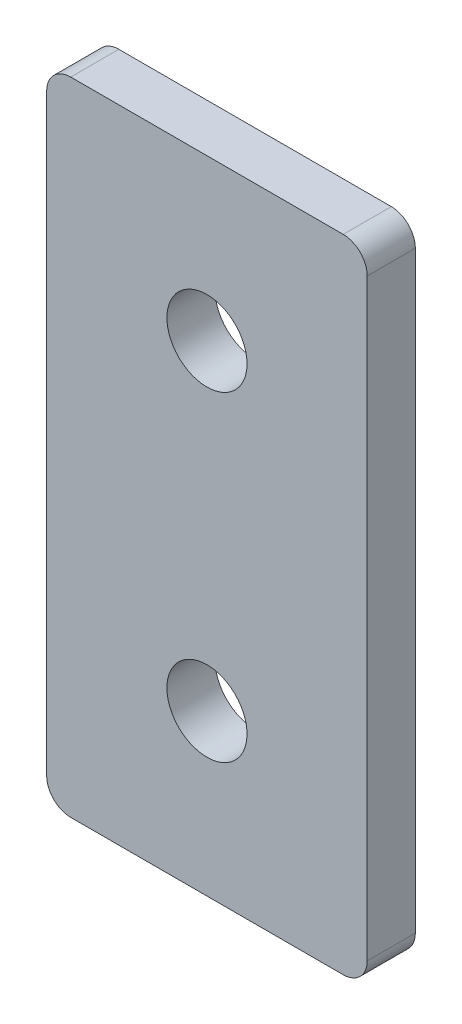
from build123d import *

# Parameters (mm, degrees)
MODEL_R             = 2.5
BOSS_EXTRUDE1_DEPTH = 3


with BuildPart() as part:
    # Model → Boss-Extrude1 (new body)
    with BuildSketch(Plane.XY):
        with BuildLine():
            Line((8.5, 0), (-8.5, 0))
            ThreePointArc((-8.5, 0), (-9.560660172, 0.439339828), (-10, 1.5))
            Line((-10, 1.5), (-10, 38.5))
            ThreePointArc((-10, 38.5), (-9.560660172, 39.560660172), (-8.5, 40))
            Line((-8.5, 40), (8.5, 40))
            ThreePointArc((8.5, 40), (9.560660172, 39.560660172), (10, 38.5))
            Line((10, 38.5), (10, 1.5))
            ThreePointArc((10, 1.5), (9.560660172, 0.439339828), (8.5, 0))
        make_face()
        with Locations((0, 30)):
            Circle(MODEL_R, mode=Mode.SUBTRACT)
        with Locations((0, 10)):
            Circle(MODEL_R, mode=Mode.SUBTRACT)
    extrude(amount=BOSS_EXTRUDE1_DEPTH)


solid = part.part
